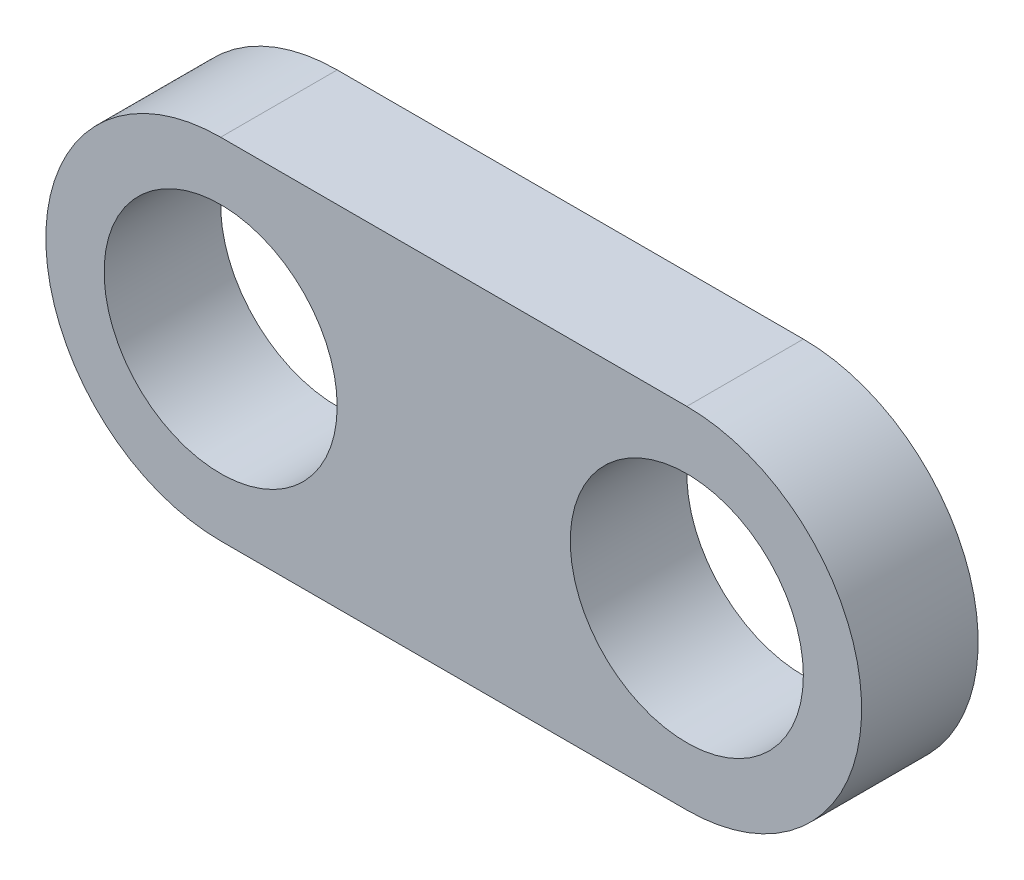
from build123d import *

# Parameters (mm, degrees)
SKETCH1_R           = 10
BOSS_EXTRUDE1_DEPTH = 10


with BuildPart() as part:
    # Sketch1 → Boss-Extrude1 (new body)
    with BuildSketch(Plane.XY):
        with BuildLine():
            Line((0, 15), (40, 15))
            ThreePointArc((40, 15), (55, 0), (40, -15))
            Line((40, -15), (0, -15))
            ThreePointArc((0, -15), (-15, 0), (0, 15))
        make_face()
        Circle(SKETCH1_R, mode=Mode.SUBTRACT)
        with Locations((40, 0)):
            Circle(SKETCH1_R, mode=Mode.SUBTRACT)
    extrude(amount=BOSS_EXTRUDE1_DEPTH)


solid = part.part
